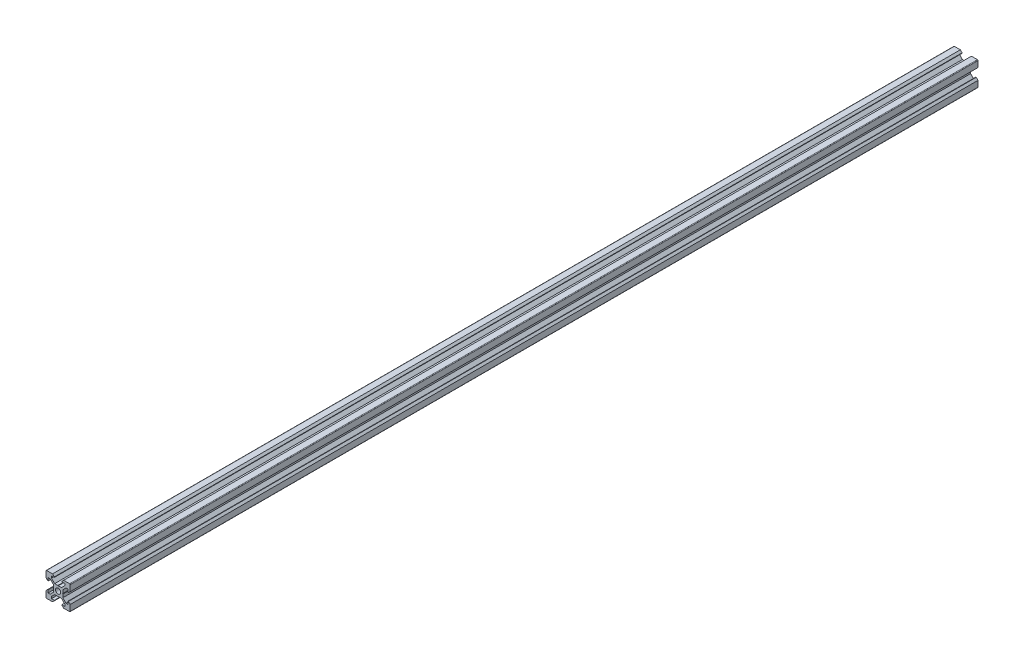
from build123d import *

# Parameters (mm, degrees)
SKETCH1_R           = 2.1
BOSS_EXTRUDE1_DEPTH = 750


with BuildPart() as part:
    # Sketch1 → Boss-Extrude1 (new body)
    with BuildSketch(Plane.XY):
        with BuildLine():
            Line((4.58, -10), (9.5, -10))
            ThreePointArc((9.5, -10), (9.853553391, -9.853553391), (10, -9.5))
            Line((10, -9.5), (10, -4.58))
            Line((10, -4.58), (8.545, -3.125))
            Line((8.545, -3.125), (8.2, -3.125))
            Line((8.2, -3.125), (8.2, -5.5))
            Line((8.2, -5.5), (6.560660172, -5.5))
            Line((6.560660172, -5.5), (3.9, -2.839339828))
            Line((3.9, -2.839339828), (3.9, -0.21))
            Line((3.9, -0.21), (3.69, 0))
            Line((3.69, 0), (3.9, 0.21))
            Line((3.9, 0.21), (3.9, 2.839339828))
            Line((3.9, 2.839339828), (6.560660172, 5.5))
            Line((6.560660172, 5.5), (8.2, 5.5))
            Line((8.2, 5.5), (8.2, 3.125))
            Line((8.2, 3.125), (8.545, 3.125))
            Line((8.545, 3.125), (10, 4.58))
            Line((10, 4.58), (10, 9.5))
            ThreePointArc((10, 9.5), (9.853553391, 9.853553391), (9.5, 10))
            Line((9.5, 10), (4.58, 10))
            Line((4.58, 10), (3.125, 8.545))
            Line((3.125, 8.545), (3.125, 8.2))
            Line((3.125, 8.2), (5.5, 8.2))
            Line((5.5, 8.2), (5.5, 6.560660172))
            Line((5.5, 6.560660172), (2.839339828, 3.9))
            Line((2.839339828, 3.9), (0.21, 3.9))
            Line((0.21, 3.9), (0, 3.69))
            Line((0, 3.69), (-0.21, 3.9))
            Line((-0.21, 3.9), (-2.839339828, 3.9))
            Line((-2.839339828, 3.9), (-5.5, 6.560660172))
            Line((-5.5, 6.560660172), (-5.5, 8.2))
            Line((-5.5, 8.2), (-3.125, 8.2))
            Line((-3.125, 8.2), (-3.125, 8.545))
            Line((-3.125, 8.545), (-4.58, 10))
            Line((-4.58, 10), (-9.5, 10))
            ThreePointArc((-9.5, 10), (-9.853553391, 9.853553391), (-10, 9.5))
            Line((-10, 9.5), (-10, 4.58))
            Line((-10, 4.58), (-8.545, 3.125))
            Line((-8.545, 3.125), (-8.2, 3.125))
            Line((-8.2, 3.125), (-8.2, 5.5))
            Line((-8.2, 5.5), (-6.560660172, 5.5))
            Line((-6.560660172, 5.5), (-3.9, 2.839339828))
            Line((-3.9, 2.839339828), (-3.9, 0.21))
            Line((-3.9, 0.21), (-3.69, 0))
            Line((-3.69, 0), (-3.9, -0.21))
            Line((-3.9, -0.21), (-3.9, -2.839339828))
            Line((-3.9, -2.839339828), (-6.560660172, -5.5))
            Line((-6.560660172, -5.5), (-8.2, -5.5))
            Line((-8.2, -5.5), (-8.2, -3.125))
            Line((-8.2, -3.125), (-8.545, -3.125))
            Line((-8.545, -3.125), (-10, -4.58))
            Line((-10, -4.58), (-10, -9.5))
            ThreePointArc((-10, -9.5), (-9.853553391, -9.853553391), (-9.5, -10))
            Line((-9.5, -10), (-4.58, -10))
            Line((-4.58, -10), (-3.125, -8.545))
            Line((-3.125, -8.545), (-3.125, -8.2))
            Line((-3.125, -8.2), (-5.5, -8.2))
            Line((-5.5, -8.2), (-5.5, -6.560660172))
            Line((-5.5, -6.560660172), (-2.839339828, -3.9))
            Line((-2.839339828, -3.9), (-0.21, -3.9))
            Line((-0.21, -3.9), (0, -3.69))
            Line((0, -3.69), (0.21, -3.9))
            Line((0.21, -3.9), (2.839339828, -3.9))
            Line((2.839339828, -3.9), (5.5, -6.560660172))
            Line((5.5, -6.560660172), (5.5, -8.2))
            Line((5.5, -8.2), (3.125, -8.2))
            Line((3.125, -8.2), (3.125, -8.545))
            Line((3.125, -8.545), (4.58, -10))
        make_face()
        Circle(SKETCH1_R, mode=Mode.SUBTRACT)
    extrude(amount=BOSS_EXTRUDE1_DEPTH)


solid = part.part
